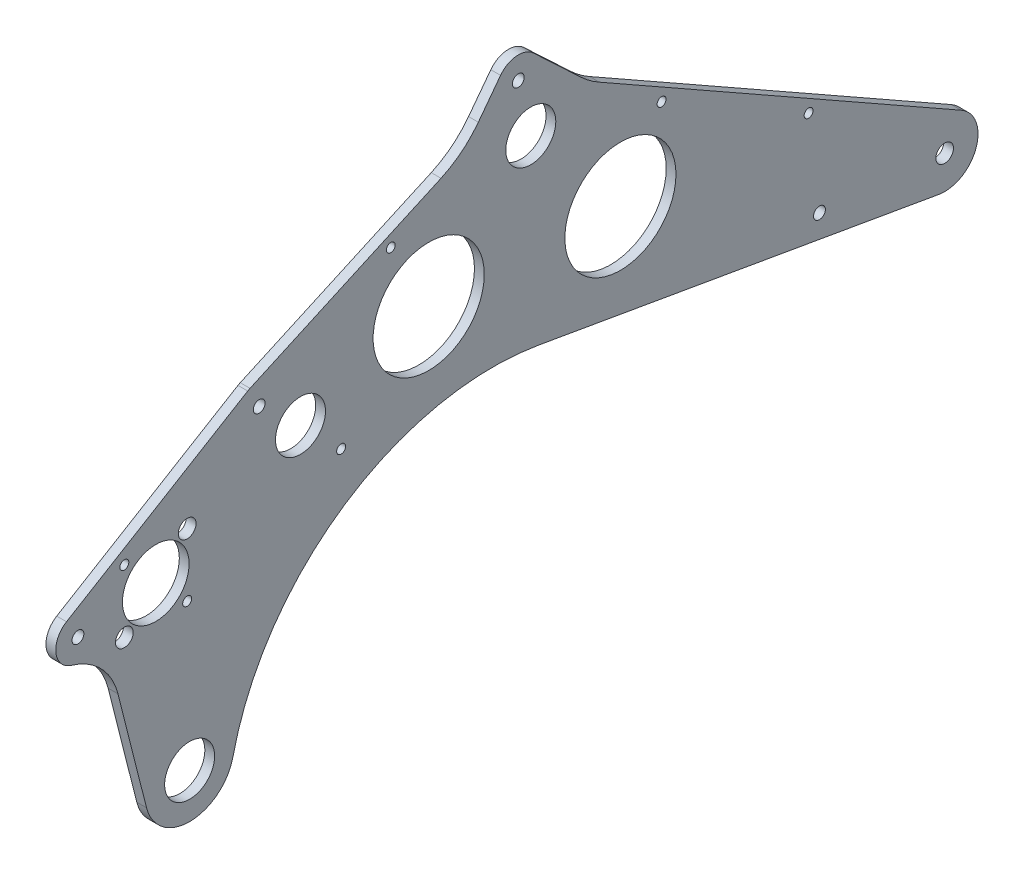
from build123d import *

# Parameters (mm, degrees)
SKETCH2_R           = 14.2875
SKETCH2_R_2         = 19.05
SKETCH2_R_3         = 2.5527
SKETCH2_R_4         = 5.0419
SKETCH2_R_5         = 3.3782
SKETCH2_R_6         = 5.08
BOSS_EXTRUDE1_DEPTH = 5.588
SKETCH4_R           = 31.75
SKETCH4_R_2         = 2.54
CUT_EXTRUDE1_DEPTH  = 6.588


with BuildPart() as part:
    # Sketch2 → Boss-Extrude1 (new body)
    with BuildSketch(Plane(origin=(0, 0, 0), x_dir=(0, 0, -1), z_dir=(1, 0, 0))):
        with BuildLine():
            Line((-456.118369633, -95.925064686), (-472.468769944, -31.298651711))
            ThreePointArc((-472.468769944, -31.298651711), (-482.016027605, -14.158478394), (-498.826247655, -4.041553364))
            ThreePointArc((-498.826247655, -4.041553364), (-507.892088549, 6.507023908), (-501.854140922, 19.037193183))
            Line((-501.854140922, 19.037193183), (-398.295274803, 81.43217891))
            ThreePointArc((-398.295274803, 81.43217891), (-397.645900343, 81.797901654), (-396.976191421, 82.124903604))
            Line((-396.976191421, 82.124903604), (-287.837435211, 131.503170214))
            ThreePointArc((-287.837435211, 131.503170214), (-276.093947879, 138.70177912), (-266.497227284, 148.582690958))
            Line((-266.497227284, 148.582690958), (-253.809934756, 165.419296806))
            ThreePointArc((-253.809934756, 165.419296806), (-244.745753976, 170.430370198), (-234.964294435, 167.025479743))
            Line((-234.964294435, 167.025479743), (-208.040592879, 141.691905515))
            ThreePointArc((-208.040592879, 141.691905515), (-202.97415121, 137.465830921), (-197.439882679, 133.87411692))
            Line((-197.439882679, 133.87411692), (9.397681692, 16.570639059))
            ThreePointArc((9.397681692, 16.570639059), (17.93346767, -6.425981428), (-3.265021391, -18.768114858))
            Line((-3.265021391, -18.768114858), (-232.00028645, 21.024135937))
            ThreePointArc((-232.00028645, 21.024135937), (-342.59010045, -2.271898683), (-406.726541812, -95.327414797))
            ThreePointArc((-406.726541812, -95.327414797), (-431.186900503, -115.093327518), (-456.118369633, -95.925064686))
        make_face()
        with Locations((-236.525067803, 126.839996455)):
            Circle(SKETCH2_R, mode=Mode.SUBTRACT)
        with Locations((-368.146285671, 49.309174015)):
            Circle(SKETCH2_R, mode=Mode.SUBTRACT)
        with Locations((-431.494222517, -89.695186775)):
            Circle(SKETCH2_R, mode=Mode.SUBTRACT)
        with Locations((-450.85, 12.7)):
            Circle(SKETCH2_R_2, mode=Mode.SUBTRACT)
        with Locations((-344.900370281, 26.063258625)):
            Circle(SKETCH2_R_3, mode=Mode.SUBTRACT)
        Circle(SKETCH2_R_4, mode=Mode.SUBTRACT)
        with Locations((-71.568668283, 6.261447138)):
            Circle(SKETCH2_R_5, mode=Mode.SUBTRACT)
        with Locations((-391.74113388, 70.554070767)):
            Circle(SKETCH2_R_5, mode=Mode.SUBTRACT)
        with Locations((-243.667263779, 157.776246012)):
            Circle(SKETCH2_R_5, mode=Mode.SUBTRACT)
        with Locations((-432.889487758, 30.660512242)):
            Circle(SKETCH2_R_6, mode=Mode.SUBTRACT)
        with Locations((-468.810512242, 30.660512242)):
            Circle(SKETCH2_R_3, mode=Mode.SUBTRACT)
        with Locations((-468.810512242, -5.260512242)):
            Circle(SKETCH2_R_6, mode=Mode.SUBTRACT)
        with Locations((-432.889487758, -5.260512242)):
            Circle(SKETCH2_R_3, mode=Mode.SUBTRACT)
        with Locations((-495.3, 8.15908504)):
            Circle(SKETCH2_R_5, mode=Mode.SUBTRACT)
    extrude(amount=BOSS_EXTRUDE1_DEPTH)

    # Sketch4 → Cut-Extrude1 (cut, through all)
    with BuildSketch(Plane(origin=(5.588, 0, 0), x_dir=(0, 0, -1), z_dir=(1, 0, 0))):
        with Locations((-294.8848929, 71.606423498)):
            Circle(SKETCH4_R)
        with Locations((-185.31249926, 66.401808093)):
            Circle(SKETCH4_R)
        with Locations((-316.523268338, 111.55499619)):
            Circle(SKETCH4_R_2)
        with Locations((-161.782656077, 106.351776712)):
            Circle(SKETCH4_R_2)
        with Locations((-77.758767474, 58.699434709)):
            Circle(SKETCH4_R_2)
    extrude(amount=-CUT_EXTRUDE1_DEPTH, mode=Mode.SUBTRACT)


solid = part.part
